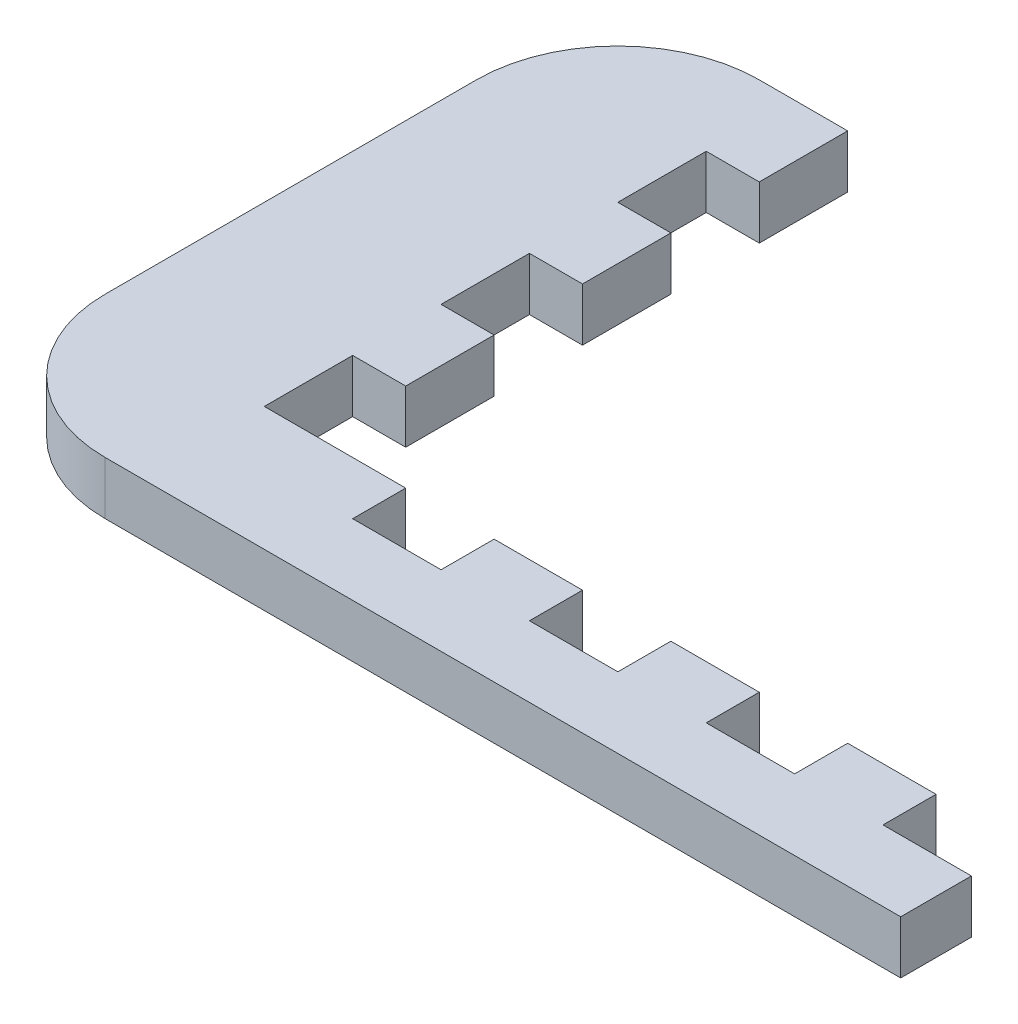
from build123d import *

# Parameters (mm, degrees)
SKETCH1_W           = 48
SKETCH1_H           = 37
BOSS_EXTRUDE1_DEPTH = 3
SKETCH3_W           = 35
SKETCH3_H           = 30
CUT_EXTRUDE1_DEPTH  = 3
SKETCH5_W           = 5
SKETCH5_H           = 3
CUT_EXTRUDE2_DEPTH  = 3
SKETCH4_W           = 5
SKETCH4_H           = 3
CUT_EXTRUDE3_DEPTH  = 3
SKETCH6_W           = 4
SKETCH6_H           = 3
BOSS_EXTRUDE2_DEPTH = 5
FILLET2_R           = 8


with BuildPart() as part:
    # Sketch1 → Boss-Extrude1 (new body)
    with BuildSketch(Plane(origin=(0, 0, 0), x_dir=(1, 0, 0), z_dir=(0, 1, 0))):
        Rectangle(SKETCH1_W, SKETCH1_H)
    extrude(amount=BOSS_EXTRUDE1_DEPTH)

    # Sketch3 → Cut-Extrude1 (cut)
    with BuildSketch(Plane(origin=(0, 3, 0), x_dir=(1, 0, 0), z_dir=(0, 1, 0))):
        with Locations((6.5, 3.5)):
            Rectangle(SKETCH3_W, SKETCH3_H)
    extrude(amount=-CUT_EXTRUDE1_DEPTH, mode=Mode.SUBTRACT)

    # Sketch5 → Cut-Extrude2 (cut)
    with BuildSketch(Plane(origin=(-11, 0, 0), x_dir=(0, 0, -1), z_dir=(1, 0, 0))):
        with Locations((11, 1.5)):
            Rectangle(SKETCH5_W, SKETCH5_H)
        with Locations((1, 1.5)):
            Rectangle(SKETCH5_W, SKETCH5_H)
        with Locations((-9, 1.5)):
            Rectangle(SKETCH5_W, SKETCH5_H)
    extrude(amount=-CUT_EXTRUDE2_DEPTH, mode=Mode.SUBTRACT)

    # Sketch4 → Cut-Extrude3 (cut)
    with BuildSketch(Plane(origin=(0, 0, 11.5), x_dir=(-1, 0, 0), z_dir=(0, 0, -1))):
        with Locations((-16.5, 1.5)):
            Rectangle(SKETCH4_W, SKETCH4_H)
        with Locations((-6.5, 1.5)):
            Rectangle(SKETCH4_W, SKETCH4_H)
        with Locations((3.5, 1.5)):
            Rectangle(SKETCH4_W, SKETCH4_H)
    extrude(amount=-CUT_EXTRUDE3_DEPTH, mode=Mode.SUBTRACT)

    # Sketch6 → Boss-Extrude2 (add)
    with BuildSketch(Plane(origin=(24, 0, 0), x_dir=(0, 0, -1), z_dir=(1, 0, 0))):
        with Locations((-16.5, 1.5)):
            Rectangle(SKETCH6_W, SKETCH6_H)
    extrude(amount=BOSS_EXTRUDE2_DEPTH)

    # Fillet2
    fillet2_edges = [part.edges().sort_by_distance(p)[0] for p in [
        (-24, 1.5, 18.5),
        (-24, 1.5, -18.5),
    ]]
    fillet(fillet2_edges, radius=FILLET2_R)


solid = part.part
